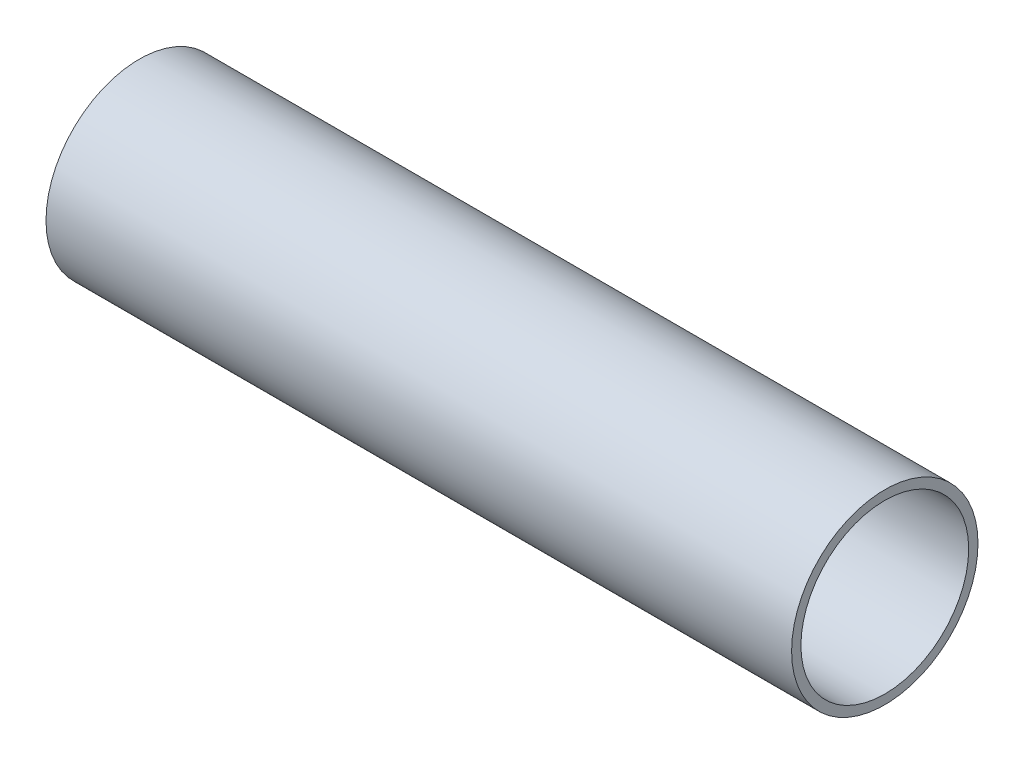
from build123d import *

# Parameters (mm, degrees)
SKETCH1_R           = 6.35
BOSS_EXTRUDE1_DEPTH = 50.8
SKETCH2_R           = 5.715
CUT_EXTRUDE1_DEPTH  = 51.8


with BuildPart() as part:
    # Sketch1 → Boss-Extrude1 (new body)
    with BuildSketch(Plane(origin=(0, 0, 0), x_dir=(0, 0, -1), z_dir=(1, 0, 0))):
        Circle(SKETCH1_R)
    extrude(amount=BOSS_EXTRUDE1_DEPTH)

    # Sketch2 → Cut-Extrude1 (cut, through all)
    with BuildSketch(Plane(origin=(50.8, 0, 0), x_dir=(0, 0, -1), z_dir=(1, 0, 0))):
        Circle(SKETCH2_R)
    extrude(amount=-CUT_EXTRUDE1_DEPTH, mode=Mode.SUBTRACT)


solid = part.part
